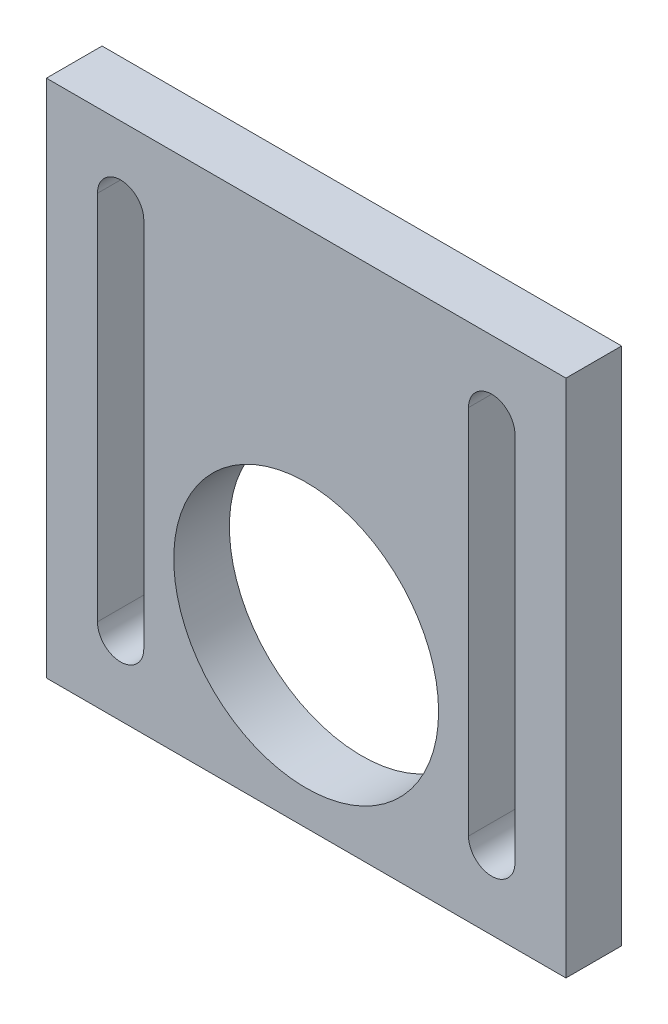
from build123d import *

# Parameters (mm, degrees)
SKETCH1_W           = 56
SKETCH1_H           = 56
BOSS_EXTRUDE1_DEPTH = 6
SKETCH2_R           = 14.275
CUT_EXTRUDE1_DEPTH  = 6


with BuildPart() as part:
    # Sketch1 → Boss-Extrude1 (new body)
    with BuildSketch(Plane.XY):
        with Locations((28, 28)):
            Rectangle(SKETCH1_W, SKETCH1_H)
    extrude(amount=BOSS_EXTRUDE1_DEPTH)

    # Sketch2 → Cut-Extrude1 (cut)
    with BuildSketch(Plane.XY.offset(6)):
        with Locations((28, 18)):
            Circle(SKETCH2_R)
        with BuildLine():
            Line((10.5, 48), (10.5, 8))
            ThreePointArc((10.5, 8), (8, 5.5), (5.5, 8))
            Line((5.5, 8), (5.5, 48))
            ThreePointArc((5.5, 48), (8, 50.5), (10.5, 48))
        make_face()
        with BuildLine():
            Line((50.5, 48), (50.5, 8))
            ThreePointArc((50.5, 8), (48, 5.5), (45.5, 8))
            Line((45.5, 8), (45.5, 48))
            ThreePointArc((45.5, 48), (48, 50.5), (50.5, 48))
        make_face()
    extrude(amount=-CUT_EXTRUDE1_DEPTH, mode=Mode.SUBTRACT)


solid = part.part
